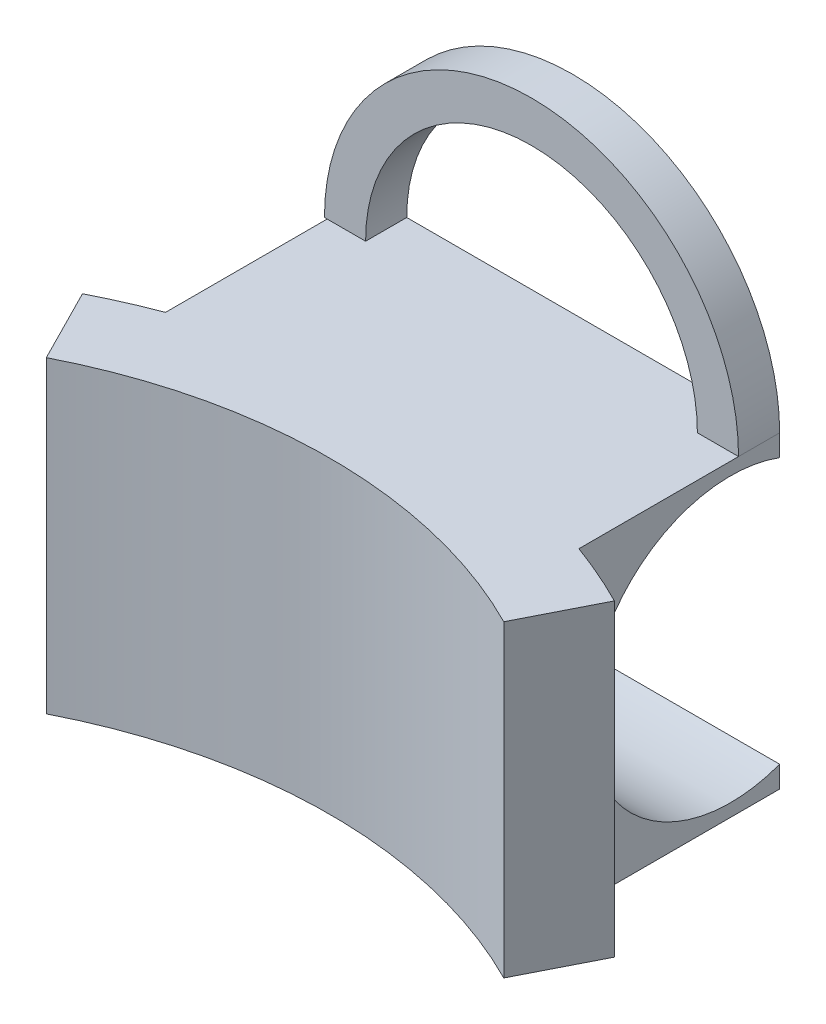
from build123d import *

# Parameters (mm, degrees)
SKETCH2_W               = 12.7
SKETCH2_H               = 6.35
BOSS_EXTRUDE1_DEPTH     = 9.525
EXTRUDE_THIN1_DEPTH     = 9.525
CUT_EXTRUDE1_DEPTH      = 16.689738362
CUT_EXTRUDE1_DEPTH_BACK = 16.689738362
SKETCH4_R               = 4.370013209
EXTRUDE_THIN3_DEPTH     = 1.27


with BuildPart() as part:
    # Sketch2 → Boss-Extrude1 (new body)
    with BuildSketch(Plane(origin=(0, 0, 0), x_dir=(1, 0, 0), z_dir=(0, 1, 0))):
        with Locations((0, -3.175)):
            Rectangle(SKETCH2_W, SKETCH2_H)
    extrude(amount=-BOSS_EXTRUDE1_DEPTH)

    # Sketch3 → Extrude-Thin1 (add)
    with BuildSketch(Plane(origin=(0, 0, 0), x_dir=(1, 0, 0), z_dir=(0, 1, 0))):
        with BuildLine():
            ThreePointArc((-6.979657819, -9.309768687), (0.081670878, -7.62), (7.142999576, -9.309768687))
            Line((7.142999576, -9.309768687), (8.292796384, -7.044913879))
            ThreePointArc((8.292796384, -7.044913879), (0.081670878, -5.08), (-8.129454628, -7.044913879))
            Line((-8.129454628, -7.044913879), (-6.979657819, -9.309768687))
        make_face()
    extrude(amount=-EXTRUDE_THIN1_DEPTH)

    # Sketch4 → Cut-Extrude1 (cut, two sides: drawn at the far end of the back side and taken through both)
    with BuildSketch(Plane(origin=(0, 0, 0), x_dir=(0, 0, -1), z_dir=(1, 0, 0)).offset(-CUT_EXTRUDE1_DEPTH_BACK)):
        with Locations((-1.517033844, -4.7625)):
            Circle(SKETCH4_R)
    extrude(amount=CUT_EXTRUDE1_DEPTH + CUT_EXTRUDE1_DEPTH_BACK, mode=Mode.SUBTRACT)

    # Sketch6 → Extrude-Thin3 (add)
    with BuildSketch(Plane.XY):
        with BuildLine():
            ThreePointArc((-6.433087898, 0), (-0.041543949, 6.391543949), (6.35, 0))
            Line((6.35, 0), (5.08, 0))
            ThreePointArc((5.08, 0), (-0.041543949, 5.121543949), (-5.163087898, 0))
            Line((-5.163087898, 0), (-6.433087898, 0))
        make_face()
    extrude(amount=EXTRUDE_THIN3_DEPTH)


solid = part.part
